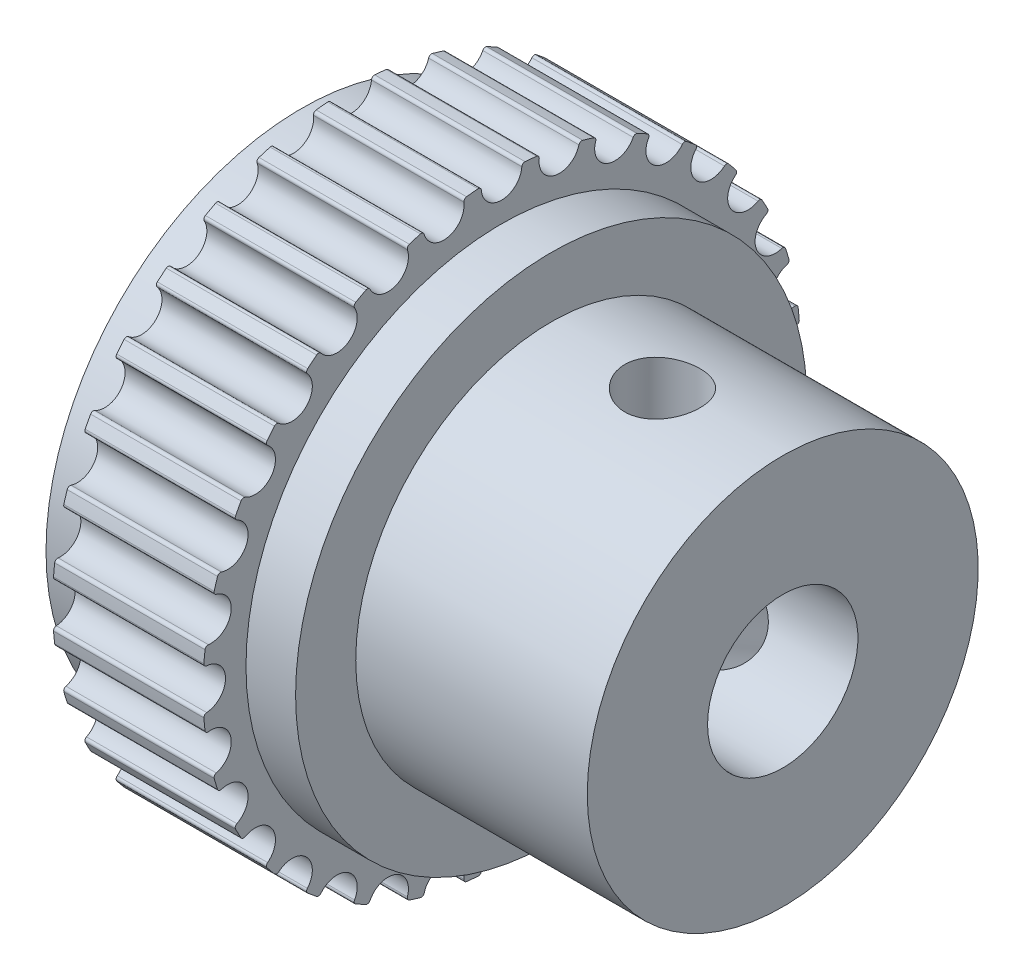
from build123d import *

# Parameters (mm, degrees)
CUT_EXTRUDE1_DEPTH       = 21.078154796
FILLET1_R                = 0.1
CIRPATTERN1_COUNT        = 32
FILLET1_OF_CIRPATTERN1_R = 0.1
TAPPED_HOLE1_REACH       = 26.959
TAPPED_HOLE1_BORE_R      = 1.25
CIRPATTERN2_COUNT        = 2
CIRPATTERN2_ANGLE        = 120


with BuildPart() as part:
    # Sketch1 → Revolve1 (revolve)
    with BuildSketch(Plane.XY, mode=Mode.PRIVATE) as revolve1_sk:
        Polygon((1.65, 9.93), (6.65, 9.93), (6.65, 8.5), (8.3, 8.5), (8.3, 6.5), (16, 6.5), (16, 2.5), (0, 2.5), (0, 8.5), (1.65, 8.5), align=None)
    revolve(revolve1_sk.sketch.rotate(Axis((0, 0, 0), (1, 0, 0)), 90), axis=Axis((0, 0, 0), (1, 0, 0)))

    # Sketch2 → Cut-Extrude1 (cut, through all)
    with BuildSketch(Plane(origin=(1.65, 0, 0), x_dir=(0, 0, -1), z_dir=(1, 0, 0))):
        with BuildLine():
            ThreePointArc((0.672980981, 9.90716895), (0, 9.93), (-0.672980981, 9.90716895))
            ThreePointArc((-0.672980981, 9.90716895), (0, 9.18), (0.672980981, 9.90716895))
        make_face()
    cut_extrude1 = extrude(amount=CUT_EXTRUDE1_DEPTH, mode=Mode.SUBTRACT)

    # Fillet1
    fillet1_edges = [part.edges().sort_by_distance(p)[0] for p in [
        (4.15, 9.90716895, 0.672980981),
        (4.15, 9.90716895, -0.672980981),
    ]]
    fillet(fillet1_edges, radius=FILLET1_R)

    # CirPattern1: Cut-Extrude1 ×32 about axis
    cirpattern1_axis = Axis((0, 0, 0), (1, 0, 0))
    for i in range(1, CIRPATTERN1_COUNT):
        add(cut_extrude1.rotate(cirpattern1_axis, i * 360 / CIRPATTERN1_COUNT), mode=Mode.SUBTRACT)

    # Fillet1 of CirPattern1
    fillet1_of_cirpattern1_edges = [part.edges().sort_by_distance(p)[0] for p in [
        (4.15, 9.5855134, 2.592842621),
        (4.15, 9.848097553, 1.272742941),
        (4.15, 8.895491946, 4.413062773),
        (4.15, 9.41056929, 3.169556065),
        (4.15, 7.863621725, 6.063691397),
        (4.15, 8.611398126, 4.944564927),
        (4.15, 6.529556932, 7.481295762),
        (4.15, 7.481295762, 6.529556932),
        (4.15, 4.944564927, 8.611398126),
        (4.15, 6.063691397, 7.863621725),
        (4.15, 3.169556065, 9.41056929),
        (4.15, 4.413062773, 8.895491946),
        (4.15, 1.272742941, 9.848097553),
        (4.15, 2.592842621, 9.5855134),
        (4.15, -0.672980981, 9.90716895),
        (4.15, 0.672980981, 9.90716895),
        (4.15, -2.592842621, 9.5855134),
        (4.15, -1.272742941, 9.848097553),
        (4.15, -4.413062773, 8.895491946),
        (4.15, -3.169556065, 9.41056929),
        (4.15, -6.063691397, 7.863621725),
        (4.15, -4.944564927, 8.611398126),
        (4.15, -7.481295762, 6.529556932),
        (4.15, -6.529556932, 7.481295762),
        (4.15, -8.611398126, 4.944564927),
        (4.15, -7.863621725, 6.063691397),
        (4.15, -9.41056929, 3.169556065),
        (4.15, -8.895491946, 4.413062773),
        (4.15, -9.848097553, 1.272742941),
        (4.15, -9.5855134, 2.592842621),
        (4.15, -9.90716895, -0.672980981),
        (4.15, -9.90716895, 0.672980981),
        (4.15, -9.5855134, -2.592842621),
        (4.15, -9.848097553, -1.272742941),
        (4.15, -8.895491946, -4.413062773),
        (4.15, -9.41056929, -3.169556065),
        (4.15, -7.863621725, -6.063691397),
        (4.15, -8.611398126, -4.944564927),
        (4.15, -6.529556932, -7.481295762),
        (4.15, -7.481295762, -6.529556932),
        (4.15, -4.944564927, -8.611398126),
        (4.15, -6.063691397, -7.863621725),
        (4.15, -3.169556065, -9.41056929),
        (4.15, -4.413062773, -8.895491946),
        (4.15, -1.272742941, -9.848097553),
        (4.15, -2.592842621, -9.5855134),
        (4.15, 0.672980981, -9.90716895),
        (4.15, -0.672980981, -9.90716895),
        (4.15, 2.592842621, -9.5855134),
        (4.15, 1.272742941, -9.848097553),
        (4.15, 4.413062773, -8.895491946),
        (4.15, 3.169556065, -9.41056929),
        (4.15, 6.063691397, -7.863621725),
        (4.15, 4.944564927, -8.611398126),
        (4.15, 7.481295762, -6.529556932),
        (4.15, 6.529556932, -7.481295762),
        (4.15, 8.611398126, -4.944564927),
        (4.15, 7.863621725, -6.063691397),
        (4.15, 9.41056929, -3.169556065),
        (4.15, 8.895491946, -4.413062773),
        (4.15, 9.848097553, -1.272742941),
        (4.15, 9.5855134, -2.592842621),
    ]]
    fillet(fillet1_of_cirpattern1_edges, radius=FILLET1_OF_CIRPATTERN1_R)

    # Tapped Hole1 bore → Tapped Hole1 (cut, up to next)
    with BuildSketch(Plane(origin=(0, 6.5, 0), x_dir=(1, 0, 0), z_dir=(0, 1, 0)), mode=Mode.PRIVATE) as tapped_hole1_sk1:
        with Locations((12, 0)):
            Circle(TAPPED_HOLE1_BORE_R)
    tapped_hole1_tool1 = extrude(tapped_hole1_sk1.sketch, amount=-TAPPED_HOLE1_REACH, mode=Mode.PRIVATE) & part.part
    tapped_hole1 = tapped_hole1_tool1.solids().sort_by_distance((12, 6.5, 0))[0]
    add(tapped_hole1, mode=Mode.SUBTRACT)

    # CirPattern2: Tapped Hole1 ×2 about axis
    cirpattern2_axis = Axis((0, 0, 0), (-1, 0, 0))
    for i in range(1, CIRPATTERN2_COUNT):
        add(tapped_hole1.rotate(cirpattern2_axis, i * CIRPATTERN2_ANGLE / (CIRPATTERN2_COUNT - 1)), mode=Mode.SUBTRACT)


solid = part.part
